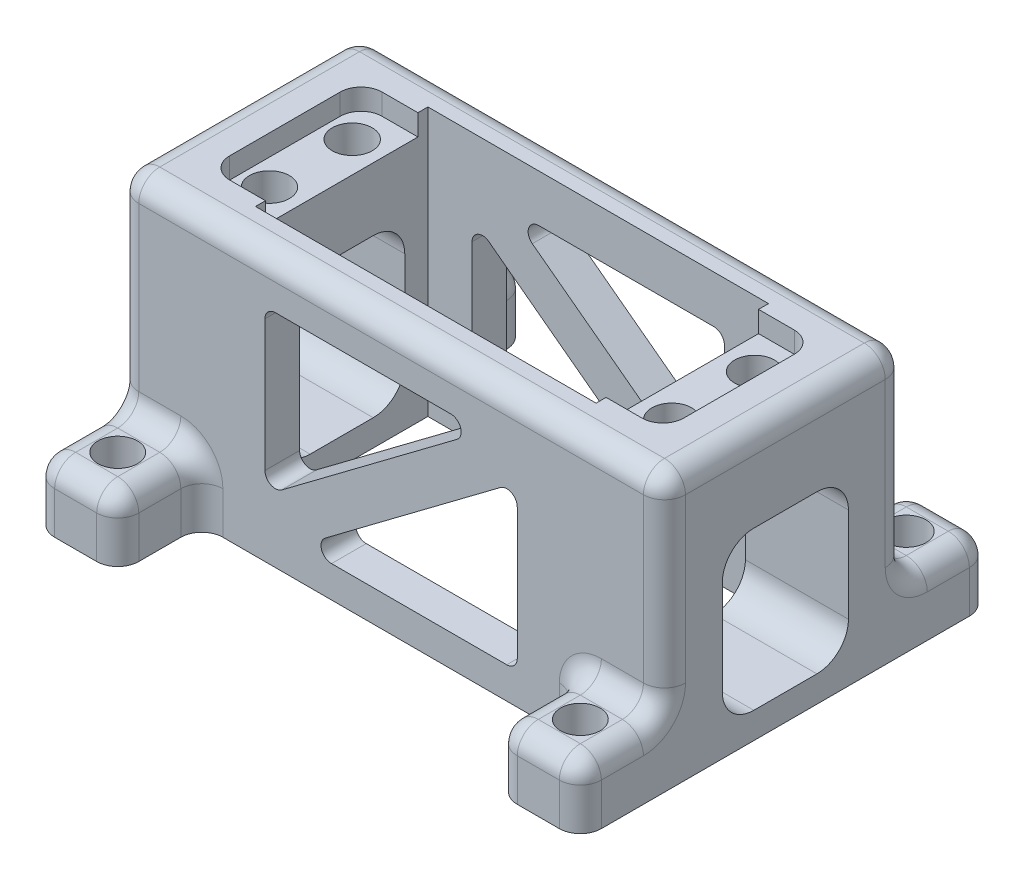
from build123d import *

# Parameters (mm, degrees)
SKETCH1_W           = 66.04
SKETCH1_H           = 29.21
SKETCH1_W_2         = 41.148
SKETCH1_H_2         = 20.828
BOSS_EXTRUDE1_DEPTH = 32.385
CUT_EXTRUDE1_DEPTH  = 2.54
SKETCH3_R           = 2.413
CUT_EXTRUDE2_DEPTH  = 10.16
SKETCH4_W           = 10.16
SKETCH4_H           = 10.16
BOSS_EXTRUDE2_DEPTH = 7.62
SKETCH5_R           = 2.3876
CUT_EXTRUDE3_DEPTH  = 33.385
FILLET1_R           = 2.54
CUT_EXTRUDE4_DEPTH  = 67.04
CUT_EXTRUDE5_REACH  = 41.37
CUT_EXTRUDE6_REACH  = 41.37


with BuildPart() as part:
    # Sketch1 → Boss-Extrude1 (new body)
    with BuildSketch(Plane(origin=(0, 0, 0), x_dir=(1, 0, 0), z_dir=(0, 1, 0))):
        Rectangle(SKETCH1_W, SKETCH1_H)
        Rectangle(SKETCH1_W_2, SKETCH1_H_2, mode=Mode.SUBTRACT)
    extrude(amount=BOSS_EXTRUDE1_DEPTH)

    # Sketch2 → Cut-Extrude1 (cut)
    with BuildSketch(Plane(origin=(0, 32.385, 0), x_dir=(1, 0, 0), z_dir=(0, 1, 0))):
        with BuildLine():
            Line((20.574, 9.2075), (24.892, 9.2075))
            ThreePointArc((24.892, 9.2075), (26.688051224, 8.463551224), (27.432, 6.6675))
            Line((27.432, 6.6675), (27.432, -6.6675))
            ThreePointArc((27.432, -6.6675), (26.688051224, -8.463551224), (24.892, -9.2075))
            Line((24.892, -9.2075), (20.574, -9.2075))
            Line((20.574, -9.2075), (20.574, 9.2075))
        make_face()
        with BuildLine():
            Line((-20.574, -9.2075), (-24.892, -9.2075))
            ThreePointArc((-24.892, -9.2075), (-26.688051224, -8.463551224), (-27.432, -6.6675))
            Line((-27.432, -6.6675), (-27.432, 6.6675))
            ThreePointArc((-27.432, 6.6675), (-26.688051224, 8.463551224), (-24.892, 9.2075))
            Line((-24.892, 9.2075), (-20.574, 9.2075))
            Line((-20.574, 9.2075), (-20.574, -9.2075))
        make_face()
    extrude(amount=-CUT_EXTRUDE1_DEPTH, mode=Mode.SUBTRACT)

    # Sketch3 → Cut-Extrude2 (cut)
    with BuildSketch(Plane(origin=(0, 29.845, 0), x_dir=(1, 0, 0), z_dir=(0, 1, 0))):
        with Locations((24.3, 5)):
            Circle(SKETCH3_R)
        with Locations((24.3, -5)):
            Circle(SKETCH3_R)
        with Locations((-24.3, -5)):
            Circle(SKETCH3_R)
        with Locations((-24.3, 5)):
            Circle(SKETCH3_R)
    extrude(amount=-CUT_EXTRUDE2_DEPTH, mode=Mode.SUBTRACT)

    # Sketch4 → Boss-Extrude2 (add)
    with BuildSketch(Plane.XZ):
        with Locations((27.94, 19.685)):
            Rectangle(SKETCH4_W, SKETCH4_H)
        with Locations((-27.94, 19.685)):
            Rectangle(SKETCH4_W, SKETCH4_H)
        with Locations((-27.94, -19.685)):
            Rectangle(SKETCH4_W, SKETCH4_H)
        with Locations((27.94, -19.685)):
            Rectangle(SKETCH4_W, SKETCH4_H)
    extrude(amount=-BOSS_EXTRUDE2_DEPTH)

    # Sketch5 → Cut-Extrude3 (cut, through all)
    with BuildSketch(Plane.XZ):
        with Locations((27.94, 19.685)):
            Circle(SKETCH5_R)
        with Locations((27.94, -19.685)):
            Circle(SKETCH5_R)
        with Locations((-27.94, -19.685)):
            Circle(SKETCH5_R)
        with Locations((-27.94, 19.685)):
            Circle(SKETCH5_R)
    extrude(amount=-CUT_EXTRUDE3_DEPTH, mode=Mode.SUBTRACT)

    # Fillet1
    fillet1_edges = [part.edges().sort_by_distance(p)[0] for p in [
        (-22.86, 3.81, -14.605),
        (-27.94, 7.62, -24.765),
        (-22.86, 3.81, -24.765),
        (-33.02, 7.62, -19.685),
        (-33.02, 3.81, -24.765),
        (-27.94, 7.62, -14.605),
        (-22.86, 7.62, -19.685),
        (27.94, 7.62, -14.605),
        (22.86, 3.81, -14.605),
        (33.02, 3.81, -24.765),
        (22.86, 7.62, -19.685),
        (22.86, 3.81, -24.765),
        (33.02, 7.62, -19.685),
        (27.94, 7.62, -24.765),
        (-33.02, 32.385, 0),
        (0, 32.385, 14.605),
        (33.02, 32.385, 0),
        (33.02, 20.0025, 14.605),
        (-33.02, 20.0025, 14.605),
        (-33.02, 20.0025, -14.605),
        (33.02, 20.0025, -14.605),
        (22.86, 3.81, 14.605),
        (27.94, 7.62, 24.765),
        (22.86, 3.81, 24.765),
        (33.02, 7.62, 19.685),
        (33.02, 3.81, 24.765),
        (27.94, 7.62, 14.605),
        (22.86, 7.62, 19.685),
        (0, 32.385, -14.605),
        (-27.94, 7.62, 14.605),
        (-22.86, 3.81, 14.605),
        (-33.02, 3.81, 24.765),
        (-22.86, 7.62, 19.685),
        (-22.86, 3.81, 24.765),
        (-33.02, 7.62, 19.685),
        (-27.94, 7.62, 24.765),
    ]]
    fillet(fillet1_edges, radius=FILLET1_R)

    # Sketch6 → Cut-Extrude4 (cut, through all)
    with BuildSketch(Plane(origin=(33.02, 0, 0), x_dir=(0, 0, -1), z_dir=(1, 0, 0))):
        with BuildLine():
            Line((-3.81, 22.225), (3.81, 22.225))
            ThreePointArc((3.81, 22.225), (6.504076836, 21.109076836), (7.62, 18.415))
            Line((7.62, 18.415), (7.62, 6.985))
            ThreePointArc((7.62, 6.985), (6.504076836, 4.290923164), (3.81, 3.175))
            Line((3.81, 3.175), (-3.81, 3.175))
            ThreePointArc((-3.81, 3.175), (-6.504076836, 4.290923164), (-7.62, 6.985))
            Line((-7.62, 6.985), (-7.62, 18.415))
            ThreePointArc((-7.62, 18.415), (-6.504076836, 21.109076836), (-3.81, 22.225))
        make_face()
    extrude(amount=-CUT_EXTRUDE4_DEPTH, mode=Mode.SUBTRACT)

    # Sketch9 → Cut-Extrude5 (cut, up to next)
    with BuildSketch(Plane(origin=(0, 0, -14.605), x_dir=(-1, 0, 0), z_dir=(0, 0, -1)), mode=Mode.PRIVATE) as cut_extrude5_sk1:
        with BuildLine():
            Line((-13.97, 26.67), (7.196666667, 26.67))
            ThreePointArc((7.196666667, 26.67), (8.401494455, 25.801609263), (7.958666667, 24.384))
            Line((7.958666667, 24.384), (-13.208, 8.509))
            ThreePointArc((-13.208, 8.509), (-14.537961266, 8.389077467), (-15.24, 9.525))
            Line((-15.24, 9.525), (-15.24, 25.4))
            ThreePointArc((-15.24, 25.4), (-14.868025612, 26.298025612), (-13.97, 26.67))
        make_face()
    cut_extrude5_tool1 = extrude(cut_extrude5_sk1.sketch, amount=-CUT_EXTRUDE5_REACH, mode=Mode.PRIVATE) & part.part
    add(cut_extrude5_tool1.solids().sort_by_distance((6.606961, 20.102283, -14.605))[0], mode=Mode.SUBTRACT)
    # Sketch9 → Cut-Extrude5 (cut, up to next)
    with BuildSketch(Plane(origin=(0, 0, -14.605), x_dir=(-1, 0, 0), z_dir=(0, 0, -1)), mode=Mode.PRIVATE) as cut_extrude5_sk2:
        with BuildLine():
            Line((-7.196666667, 3.81), (13.97, 3.81))
            ThreePointArc((13.97, 3.81), (14.868025612, 4.181974388), (15.24, 5.08))
            Line((15.24, 5.08), (15.24, 20.955))
            ThreePointArc((15.24, 20.955), (14.537961266, 22.090922533), (13.208, 21.971))
            Line((13.208, 21.971), (-7.958666667, 6.096))
            ThreePointArc((-7.958666667, 6.096), (-8.401494455, 4.678390737), (-7.196666667, 3.81))
        make_face()
    cut_extrude5_tool2 = extrude(cut_extrude5_sk2.sketch, amount=-CUT_EXTRUDE5_REACH, mode=Mode.PRIVATE) & part.part
    add(cut_extrude5_tool2.solids().sort_by_distance((-6.606961, 10.377717, -14.605))[0], mode=Mode.SUBTRACT)

    # Sketch10 → Cut-Extrude6 (cut, up to next)
    with BuildSketch(Plane.XY.offset(14.605), mode=Mode.PRIVATE) as cut_extrude6_sk1:
        with BuildLine():
            ThreePointArc((13.208, 21.971), (14.537961266, 22.090922533), (15.24, 20.955))
            Line((15.24, 20.955), (15.24, 5.08))
            ThreePointArc((15.24, 5.08), (14.868025612, 4.181974388), (13.97, 3.81))
            Line((13.97, 3.81), (-7.196666667, 3.81))
            ThreePointArc((-7.196666667, 3.81), (-8.401494455, 4.678390737), (-7.958666667, 6.096))
            Line((-7.958666667, 6.096), (13.208, 21.971))
        make_face()
    cut_extrude6_tool1 = extrude(cut_extrude6_sk1.sketch, amount=-CUT_EXTRUDE6_REACH, mode=Mode.PRIVATE) & part.part
    add(cut_extrude6_tool1.solids().sort_by_distance((6.606961, 10.377717, 14.605))[0], mode=Mode.SUBTRACT)
    # Sketch10 → Cut-Extrude6 (cut, up to next)
    with BuildSketch(Plane.XY.offset(14.605), mode=Mode.PRIVATE) as cut_extrude6_sk2:
        with BuildLine():
            Line((-13.97, 26.67), (7.196666667, 26.67))
            ThreePointArc((7.196666667, 26.67), (8.401494455, 25.801609263), (7.958666667, 24.384))
            Line((7.958666667, 24.384), (-13.208, 8.509))
            ThreePointArc((-13.208, 8.509), (-14.537961266, 8.389077467), (-15.24, 9.525))
            Line((-15.24, 9.525), (-15.24, 25.4))
            ThreePointArc((-15.24, 25.4), (-14.868025612, 26.298025612), (-13.97, 26.67))
        make_face()
    cut_extrude6_tool2 = extrude(cut_extrude6_sk2.sketch, amount=-CUT_EXTRUDE6_REACH, mode=Mode.PRIVATE) & part.part
    add(cut_extrude6_tool2.solids().sort_by_distance((-6.606961, 20.102283, 14.605))[0], mode=Mode.SUBTRACT)


solid = part.part
